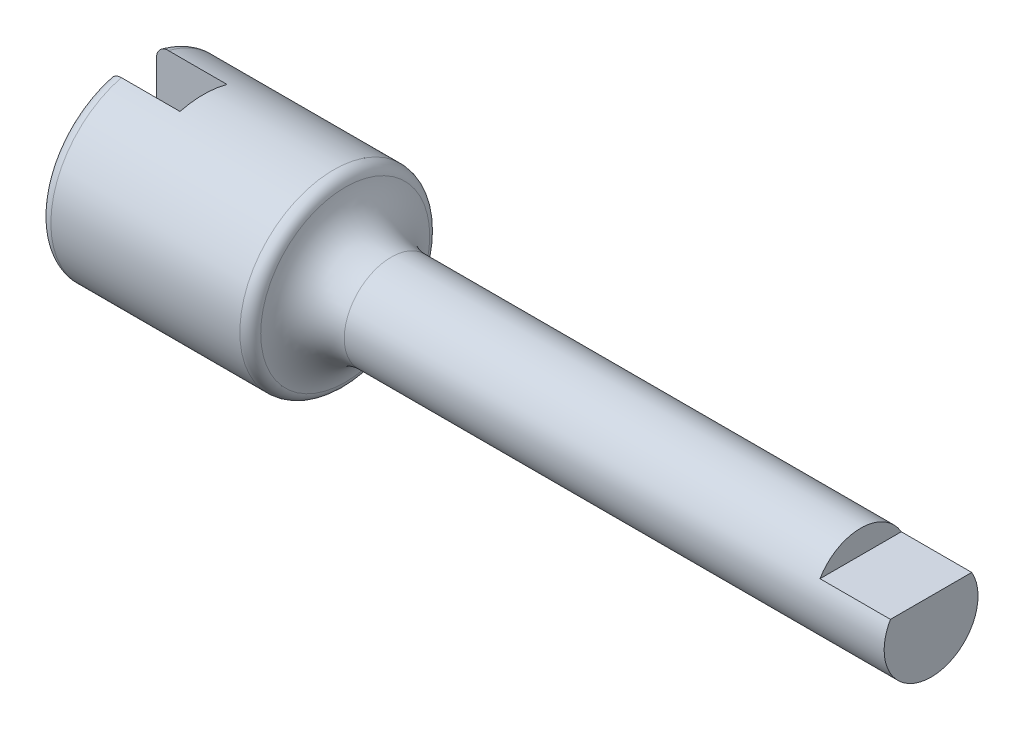
from build123d import *

# Parameters (mm, degrees)
SKETCH2_W          = 2
SKETCH2_H          = 8
CUT_EXTRUDE1_DEPTH = 3
FILLET1_R          = 0.5
SKETCH3_W          = 3
SKETCH3_H          = 1
CUT_EXTRUDE2_DEPTH = 4


with BuildPart() as part:
    # Sketch1 → Revolve1 (revolve)
    with BuildSketch(Plane.XY):
        with BuildLine():
            Line((0, 0), (0, 4))
            Line((0, 4), (9, 4))
            ThreePointArc((9, 4), (9.585786438, 2.585786438), (11, 2))
            Line((11, 2), (34, 2))
            Line((34, 2), (34, 0))
            Line((34, 0), (0, 0))
        make_face()
    revolve(axis=Axis((0, 0, 0), (1, 0, 0)))

    # Sketch2 → Cut-Extrude1 (cut)
    with BuildSketch(Plane.ZY):
        Rectangle(SKETCH2_W, SKETCH2_H)
    extrude(amount=-CUT_EXTRUDE1_DEPTH, mode=Mode.SUBTRACT)

    # Fillet1
    fillet1_edges = [part.edges().sort_by_distance(p)[0] for p in [
        (0, 0, -4),
        (0, 0, 4),
        (9, -4, 0),
    ]]
    fillet(fillet1_edges, radius=FILLET1_R)

    # Sketch3 → Cut-Extrude2 (cut, symmetric)
    with BuildSketch(Plane.XY):
        with Locations((32.5, 1.5)):
            Rectangle(SKETCH3_W, SKETCH3_H)
    extrude(amount=CUT_EXTRUDE2_DEPTH, both=True, mode=Mode.SUBTRACT)


solid = part.part
